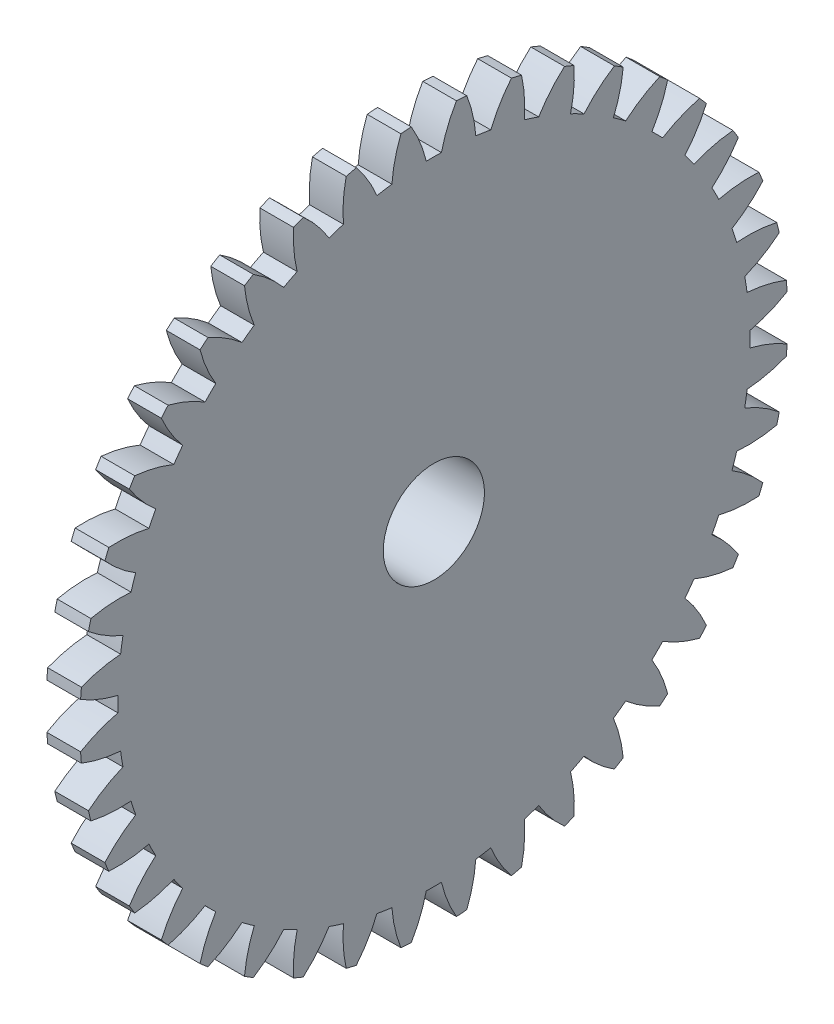
from build123d import *

# Parameters (mm, degrees)
BASPROSKE_W      = 2
BASPROSKE_H      = 21
TOOTHCUT_DEPTH   = 30.765752132
TEETHCUTS_COUNT  = 40
TEETHCUTS_ANGLE  = 351
HUBNEAONESKE_R   = 9
HUBNEARONE_DEPTH = 4.0000508
BORSKE_R         = 3
BORE_DEPTH       = 6.0000508


with BuildPart() as part:
    # BasProSke → Base-Revolve (revolve)
    with BuildSketch(Plane(origin=(0, 0, 0), x_dir=(1, 0, 0), z_dir=(0, 1, 0)), mode=Mode.PRIVATE) as base_revolve_sk:
        with Locations((1, 10.5)):
            Rectangle(BASPROSKE_W, BASPROSKE_H)
    revolve(base_revolve_sk.sketch.rotate(Axis((-10, 0, 0), (1, 0, 0)), 180), axis=Axis((-10, 0, 0), (1, 0, 0)))

    # TooCutSke → ToothCut (cut, through all)
    with BuildSketch(Plane(origin=(0, 0, 0), x_dir=(0, 0, -1), z_dir=(1, 0, 0))):
        with BuildLine():
            ThreePointArc((0.448673268, 18.74363074), (0, 18.749), (-0.448673268, 18.74363074))
            ThreePointArc((-0.448673268, 18.74363074), (-0.816786816, 19.89705013), (-1.354745081, 20.981708961))
            ThreePointArc((-1.354745081, 20.981708961), (0, 21.0254), (1.354745081, 20.981708961))
            ThreePointArc((1.354745081, 20.981708961), (0.816786816, 19.89705013), (0.448673268, 18.74363074))
        make_face()
    toothcut = extrude(amount=TOOTHCUT_DEPTH, mode=Mode.SUBTRACT)

    # TeethCuts: ToothCut ×40 about axis
    teethcuts_axis = Axis((-10, 0, 0), (1, 0, 0))
    for i in range(1, TEETHCUTS_COUNT):
        add(toothcut.rotate(teethcuts_axis, i * TEETHCUTS_ANGLE / (TEETHCUTS_COUNT - 1)), mode=Mode.SUBTRACT)

    # HubNeaOneSke → HubNearOne (add)
    with BuildSketch(Plane.ZY):
        with Locations(Location((0, 0, 0), (0, 0, 180))):
            Circle(HUBNEAONESKE_R)
    extrude(amount=HUBNEARONE_DEPTH)

    # BorSke → Bore (cut, symmetric)
    with BuildSketch(Plane(origin=(0, 0, 0), x_dir=(0, 0, -1), z_dir=(1, 0, 0))):
        with Locations(Location((0, 0, 0), (0, 0, 180))):
            Circle(BORSKE_R)
    extrude(amount=BORE_DEPTH, both=True, mode=Mode.SUBTRACT)


solid = part.part
